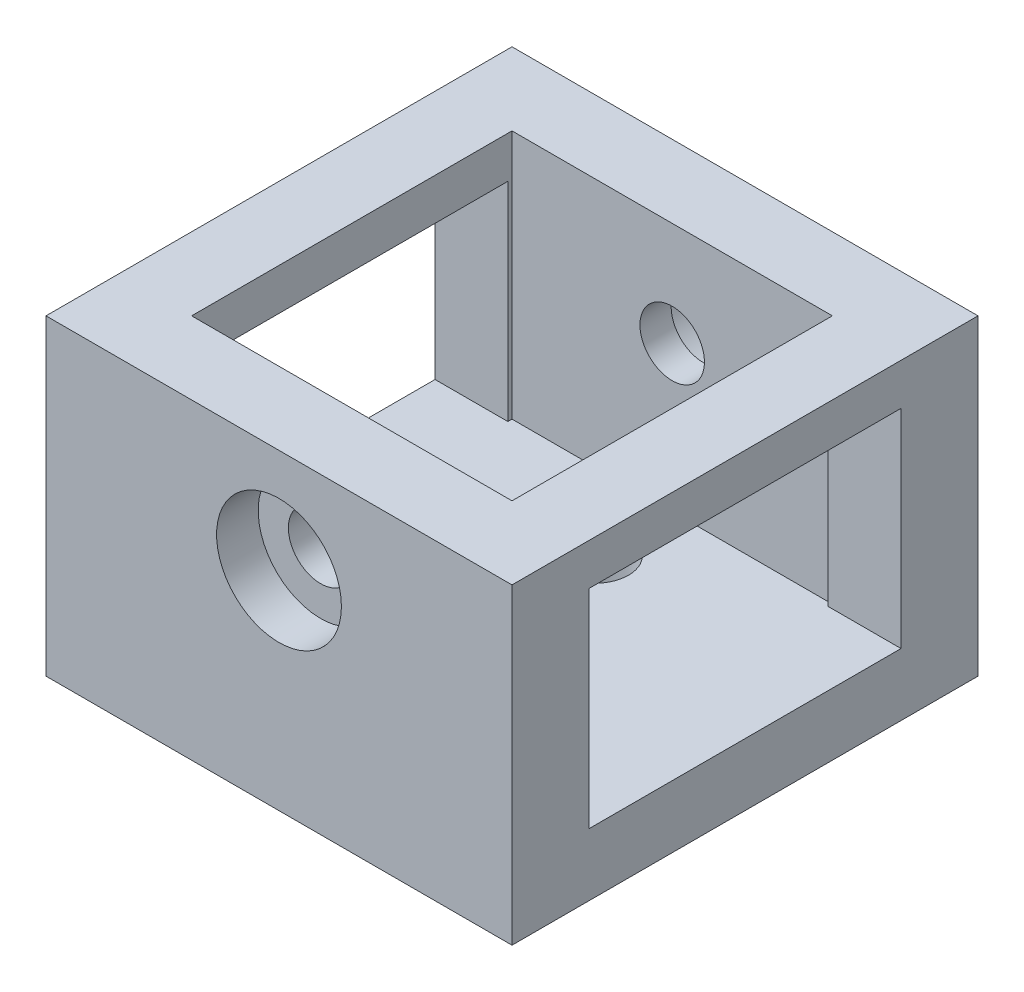
from build123d import *

# Parameters (mm, degrees)
SKETCH_1_W          = 15.4
SKETCH_1_H          = 22.4
EXTRUDE_2_DEPTH     = 3
SKETCH_1_4_W        = 15.4
SKETCH_1_4_H        = 3.5
EXTRUDE_3_DEPTH     = 5
EXTRUDE_3_2_DEPTH   = 5
SKETCH_1_5_W        = 22.4
SKETCH_1_5_H        = 22.4
SKETCH_1_5_W_2      = 15.4
SKETCH_1_5_H_2      = 15.4
EXTRUDE_4_DEPTH     = 15
SKETCH_3_R          = 1.55
CUT_EXTRUDE_2_DEPTH = 37.042752392
SKETCH_9_R          = 1.6
CUT_EXTRUDE_6_DEPTH = 22.81467396
SKETCH_10_R         = 3
CUT_EXTRUDE_7_DEPTH = 2
CUT_EXTRUDE_START   = -2
SKETCH_11_R         = 3
CUT_EXTRUDE_8_DEPTH = 2
CUT_EXTRUDE_9_DEPTH = 30.192464781


with BuildPart() as part:
    # 草图1 → 凸台-拉伸2 (new body)
    with BuildSketch(Plane(origin=(0, 0, 0), x_dir=(1, 0, 0), z_dir=(0, 1, 0))):
        Rectangle(SKETCH_1_W, SKETCH_1_H)
    extrude(amount=EXTRUDE_2_DEPTH)



with BuildPart() as body_2:
    # 草图1<4> → 凸台-拉伸3 (new body)
    with BuildSketch(Plane(origin=(0, 0, 0), x_dir=(1, 0, 0), z_dir=(0, 1, 0))):
        with Locations((0, 9.45)):
            Rectangle(SKETCH_1_4_W, SKETCH_1_4_H)
    extrude(amount=EXTRUDE_3_DEPTH)


with BuildPart() as body_3:
    # 草图1<4> → Extrude 3 2 (new body)
    with BuildSketch(Plane(origin=(0, 0, 0), x_dir=(1, 0, 0), z_dir=(0, 1, 0))):
        with Locations((0, -9.45)):
            Rectangle(SKETCH_1_4_W, SKETCH_1_4_H)
    extrude(amount=EXTRUDE_3_2_DEPTH)


with BuildPart() as part_1:
    add(part.part)

    add(body_2.part)  # 凸台-拉伸4 merges body 2

    add(body_3.part)  # 凸台-拉伸4 merges body 3
    # 草图1<5> → 凸台-拉伸4 (add)
    with BuildSketch(Plane(origin=(0, 0, 0), x_dir=(1, 0, 0), z_dir=(0, 1, 0))):
        Rectangle(SKETCH_1_5_W, SKETCH_1_5_H)
        Rectangle(SKETCH_1_5_W_2, SKETCH_1_5_H_2, mode=Mode.SUBTRACT)
    extrude(amount=EXTRUDE_4_DEPTH)

    # 草图3 → 切除-拉伸2 (cut, through all)
    with BuildSketch(Plane(origin=(0, 0, -19.6), x_dir=(-1, 0, 0), z_dir=(0, 0, -1))):
        with Locations((0, 10)):
            Circle(SKETCH_3_R)
    extrude(amount=-CUT_EXTRUDE_2_DEPTH, mode=Mode.SUBTRACT)

    # 草图9 → 切除-拉伸6 (cut, through all)
    with BuildSketch(Plane.XZ):
        with Locations((0, 4)):
            Circle(SKETCH_9_R)
        with Locations((0, -4)):
            Circle(SKETCH_9_R)
    extrude(amount=-CUT_EXTRUDE_6_DEPTH, mode=Mode.SUBTRACT)

    # 草图10 → 切除-拉伸7 (cut)
    with BuildSketch(Plane(origin=(0, 0, -11.2), x_dir=(-1, 0, 0), z_dir=(0, 0, -1))):
        with Locations((0, 10)):
            Circle(SKETCH_10_R)
    extrude(amount=-CUT_EXTRUDE_7_DEPTH, mode=Mode.SUBTRACT)

    # 草图11 → 切除-拉伸8 (cut)
    with BuildSketch(Plane.XY.offset(11.2).offset(CUT_EXTRUDE_START)):
        with Locations((0, 10)):
            Circle(SKETCH_11_R)
    extrude(amount=CUT_EXTRUDE_8_DEPTH, mode=Mode.SUBTRACT)

    # 草图8 → 切除-拉伸9 (cut, through all)
    with BuildSketch(Plane.ZY.offset(11.2)):
        Polygon((7.5, 10), (7.5, 3), (0, 3), (-7.5, 3), (-7.5, 13), (7.5, 13), align=None)
    extrude(amount=-CUT_EXTRUDE_9_DEPTH, mode=Mode.SUBTRACT)


solid = part_1.part
